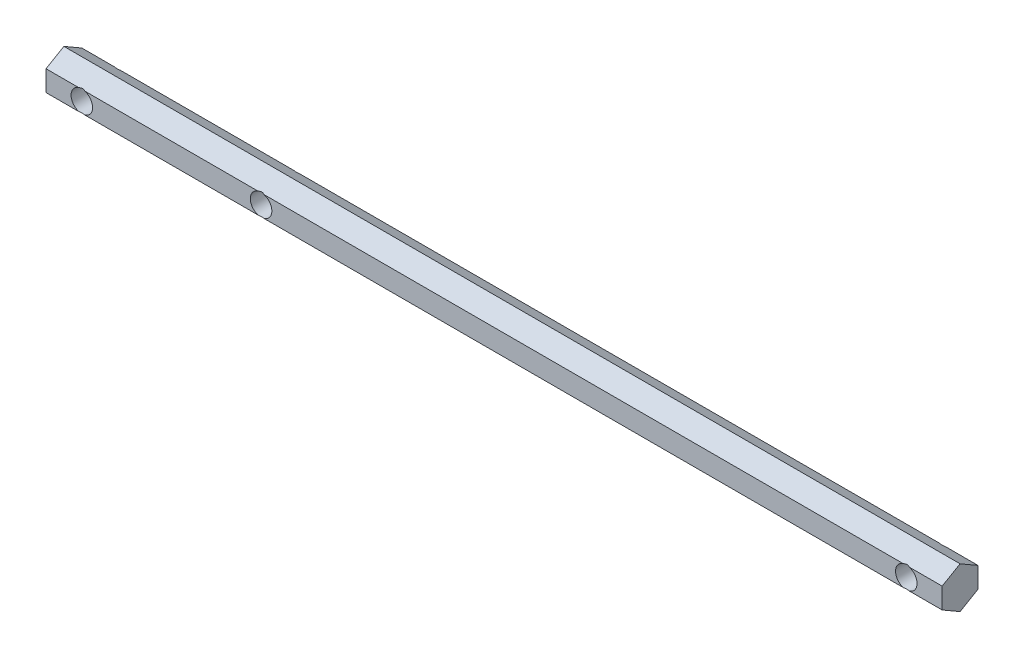
from build123d import *

# Parameters (mm, degrees)
BOSS_EXTRUDE1_DEPTH     = 125
SKETCH2_R               = 3
CUT_EXTRUDE1_DEPTH      = 6
CUT_EXTRUDE1_DEPTH_BACK = 6


with BuildPart() as part:
    # Sketch1 → Boss-Extrude1 (new body, symmetric)
    with BuildSketch(Plane(origin=(0, 0, 0), x_dir=(0, 0, -1), z_dir=(1, 0, 0))):
        Polygon((0, 5.773502692), (-5, 2.886751346), (-5, -2.886751346), (0, -5.773502692), (5, -2.886751346), (5, 2.886751346), align=None)
    extrude(amount=BOSS_EXTRUDE1_DEPTH, both=True)

    # Sketch2 → Cut-Extrude1 (cut, two sides)
    with BuildSketch(Plane.XY) as cut_extrude1_sk:
        with Locations((115, 0)):
            Circle(SKETCH2_R)
        with Locations((-115, 0)):
            Circle(SKETCH2_R)
        with Locations((-65, 0)):
            Circle(SKETCH2_R)
    extrude(amount=CUT_EXTRUDE1_DEPTH, mode=Mode.SUBTRACT)
    extrude(cut_extrude1_sk.sketch, amount=-CUT_EXTRUDE1_DEPTH_BACK, mode=Mode.SUBTRACT)


solid = part.part
